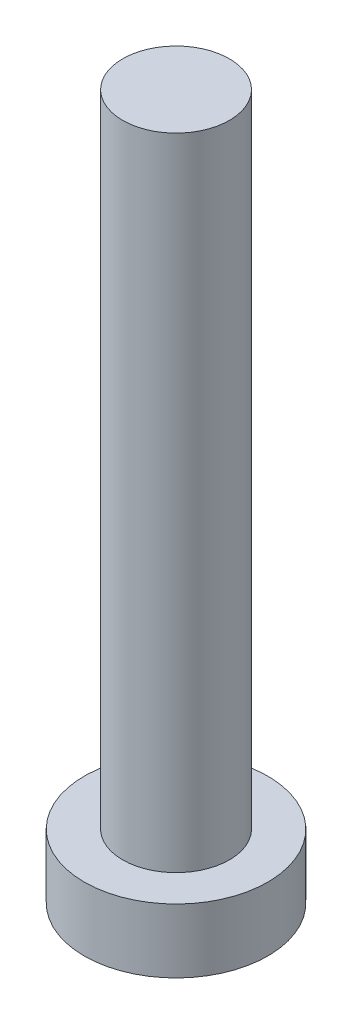
from build123d import *

# Parameters (mm, degrees)
SKETCH_1_R          = 4.3
EXTRUDE_1_DEPTH     = 3
SKETCH_2_R          = 2.5
EXTRUDE_2_DEPTH     = 30
CUT_EXTRUDE_1_DEPTH = 1.5


with BuildPart() as part:
    # 草图1 → 凸台-拉伸1 (new body)
    with BuildSketch(Plane(origin=(0, 0, 0), x_dir=(1, 0, 0), z_dir=(0, 1, 0))):
        Circle(SKETCH_1_R)
    extrude(amount=EXTRUDE_1_DEPTH)

    # 草图2 → 凸台-拉伸2 (add)
    with BuildSketch(Plane(origin=(0, 3, 0), x_dir=(1, 0, 0), z_dir=(0, 1, 0))):
        Circle(SKETCH_2_R)
    extrude(amount=EXTRUDE_2_DEPTH)

    # 草图3 → 切除-拉伸1 (cut)
    with BuildSketch(Plane.XZ):
        with BuildLine():
            Line((-0.6, 1.1), (-0.6, 2.4))
            Line((-0.6, 2.4), (0.6, 2.4))
            Line((0.6, 2.4), (0.6, 1.1))
            ThreePointArc((0.6, 1.1), (0.746446609, 0.746446609), (1.1, 0.6))
            Line((1.1, 0.6), (2.4, 0.6))
            Line((2.4, 0.6), (2.4, -0.6))
            Line((2.4, -0.6), (1.1, -0.6))
            ThreePointArc((1.1, -0.6), (0.746446609, -0.746446609), (0.6, -1.1))
            Line((0.6, -1.1), (0.6, -2.4))
            Line((0.6, -2.4), (-0.6, -2.4))
            Line((-0.6, -2.4), (-0.6, -1.1))
            ThreePointArc((-0.6, -1.1), (-0.746446609, -0.746446609), (-1.1, -0.6))
            Line((-1.1, -0.6), (-2.4, -0.6))
            Line((-2.4, -0.6), (-2.4, 0.6))
            Line((-2.4, 0.6), (-1.1, 0.6))
            ThreePointArc((-1.1, 0.6), (-0.746446609, 0.746446609), (-0.6, 1.1))
        make_face()
    extrude(amount=-CUT_EXTRUDE_1_DEPTH, mode=Mode.SUBTRACT)


solid = part.part
